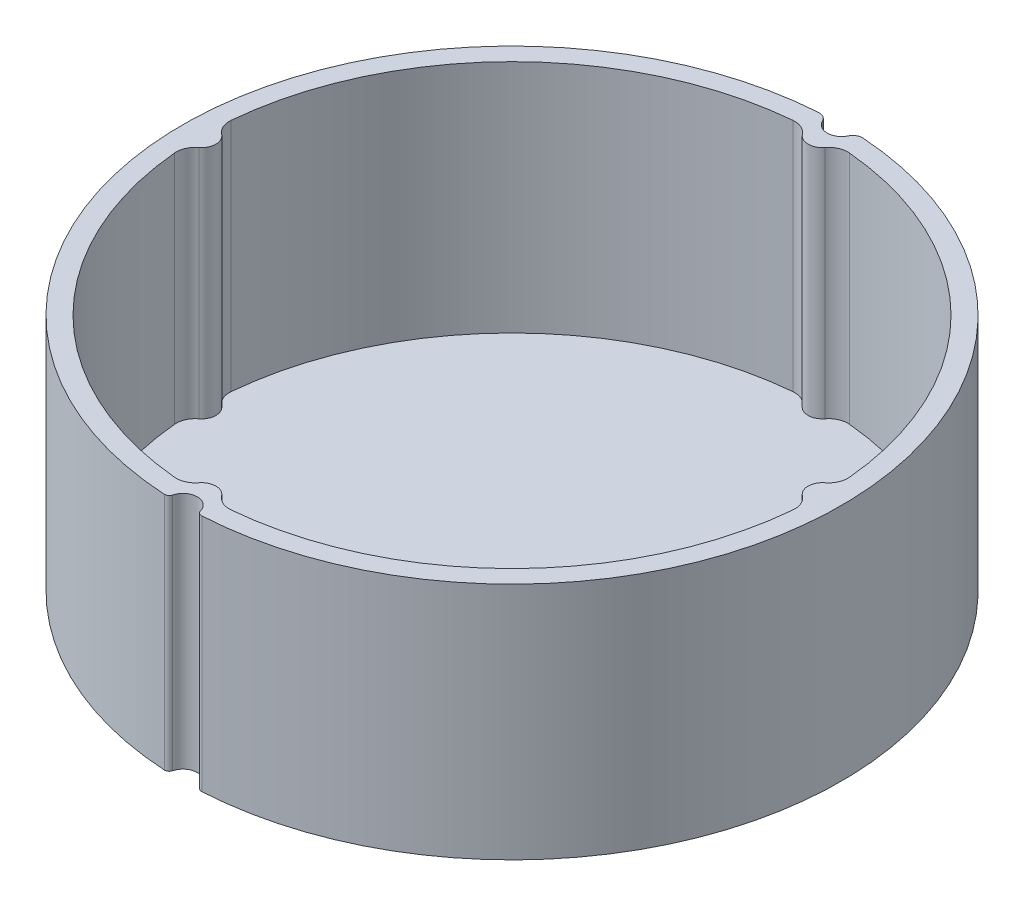
from build123d import *

# Parameters (mm, degrees)
BOSS_EXTRUDE1_DEPTH = 25
CUT_EXTRUDE2_DEPTH  = 55.786493398
BOSS_EXTRUDE2_DEPTH = 0.4


with BuildPart() as part:
    # Sketch1 → Boss-Extrude1 (new body)
    with BuildSketch(Plane(origin=(0, 0, 0), x_dir=(1, 0, 0), z_dir=(0, 1, 0))):
        with BuildLine():
            ThreePointArc((1.451818925, -34.068556857), (1.641248992, -34.346908706), (1.964225605, -34.442038138))
            ThreePointArc((1.964225605, -34.442038138), (26.591847487, -21.978073076), (34.198225299, 4.555174015))
            ThreePointArc((34.198225299, 4.555174015), (23.590291339, 25.176355888), (2.324135821, 34.423627607))
            ThreePointArc((2.324135821, 34.423627607), (1.751838249, 34.289058819), (1.354061739, 33.856153382))
            ThreePointArc((1.354061739, 33.856153382), (0, 33.001534515), (-1.354061739, 33.856153382))
            ThreePointArc((-1.354061739, 33.856153382), (-1.751838249, 34.289058819), (-2.324135821, 34.423627607))
            ThreePointArc((-2.324135821, 34.423627607), (-23.590291339, 25.176355888), (-34.198225299, 4.555174015))
            ThreePointArc((-34.198225299, 4.555174015), (-26.591847487, -21.978073076), (-1.964225605, -34.442038138))
            ThreePointArc((-1.964225605, -34.442038138), (-1.641248992, -34.346908706), (-1.451818925, -34.068556857))
            ThreePointArc((-1.451818925, -34.068556857), (0, -32.945679925), (1.451818925, -34.068556857))
        make_face()
        with BuildLine():
            Line((-2.417, 3.787737139), (0, 3.787737139))
            Line((0, 3.787737139), (2.417, 3.787737139))
            ThreePointArc((2.417, 3.787737139), (0, -4.489512172), (-2.417, 3.787737139))
        make_face(mode=Mode.SUBTRACT)
    extrude(amount=BOSS_EXTRUDE1_DEPTH)

    # Sketch2 → Cut-Extrude2 (cut, through all)
    with BuildSketch(Plane(origin=(0, 0, 0), x_dir=(1, 0, 0), z_dir=(0, 1, 0))):
        with BuildLine():
            ThreePointArc((-32.364754098, -2.961873082), (-22.980970389, -22.980970389), (-2.961873082, -32.364754098))
            ThreePointArc((-2.961873082, -32.364754098), (-1.976534873, -32.204764677), (-1.191258844, -31.588461538))
            ThreePointArc((-1.191258844, -31.588461538), (0, -31), (1.191258844, -31.588461538))
            ThreePointArc((1.191258844, -31.588461538), (1.976534873, -32.204764677), (2.961873082, -32.364754098))
            ThreePointArc((2.961873082, -32.364754098), (22.980970389, -22.980970389), (32.364754098, -2.961873082))
            ThreePointArc((32.364754098, -2.961873082), (32.204764677, -1.976534873), (31.588461538, -1.191258844))
            ThreePointArc((31.588461538, -1.191258844), (31, 0), (31.588461538, 1.191258844))
            ThreePointArc((31.588461538, 1.191258844), (32.204764677, 1.976534873), (32.364754098, 2.961873082))
            ThreePointArc((32.364754098, 2.961873082), (22.980970389, 22.980970389), (2.961873082, 32.364754098))
            ThreePointArc((2.961873082, 32.364754098), (1.976534873, 32.204764677), (1.191258844, 31.588461538))
            ThreePointArc((1.191258844, 31.588461538), (0, 31), (-1.191258844, 31.588461538))
            ThreePointArc((-1.191258844, 31.588461538), (-1.976534873, 32.204764677), (-2.961873082, 32.364754098))
            ThreePointArc((-2.961873082, 32.364754098), (-22.980970389, 22.980970389), (-32.364754098, 2.961873082))
            ThreePointArc((-32.364754098, 2.961873082), (-32.204764677, 1.976534873), (-31.588461538, 1.191258844))
            ThreePointArc((-31.588461538, 1.191258844), (-31, 0), (-31.588461538, -1.191258844))
            ThreePointArc((-31.588461538, -1.191258844), (-32.204764677, -1.976534873), (-32.364754098, -2.961873082))
        make_face()
    extrude(amount=CUT_EXTRUDE2_DEPTH, mode=Mode.SUBTRACT)

    # Sketch2_2 → Boss-Extrude2 (add)
    with BuildSketch(Plane(origin=(0, 0, 0), x_dir=(1, 0, 0), z_dir=(0, 1, 0))):
        with BuildLine():
            ThreePointArc((-32.364754098, -2.961873082), (-22.980970389, -22.980970389), (-2.961873082, -32.364754098))
            ThreePointArc((-2.961873082, -32.364754098), (-1.976534873, -32.204764677), (-1.191258844, -31.588461538))
            ThreePointArc((-1.191258844, -31.588461538), (0, -31), (1.191258844, -31.588461538))
            ThreePointArc((1.191258844, -31.588461538), (1.976534873, -32.204764677), (2.961873082, -32.364754098))
            ThreePointArc((2.961873082, -32.364754098), (22.980970389, -22.980970389), (32.364754098, -2.961873082))
            ThreePointArc((32.364754098, -2.961873082), (32.204764677, -1.976534873), (31.588461538, -1.191258844))
            ThreePointArc((31.588461538, -1.191258844), (31, 0), (31.588461538, 1.191258844))
            ThreePointArc((31.588461538, 1.191258844), (32.204764677, 1.976534873), (32.364754098, 2.961873082))
            ThreePointArc((32.364754098, 2.961873082), (22.980970389, 22.980970389), (2.961873082, 32.364754098))
            ThreePointArc((2.961873082, 32.364754098), (1.976534873, 32.204764677), (1.191258844, 31.588461538))
            ThreePointArc((1.191258844, 31.588461538), (0, 31), (-1.191258844, 31.588461538))
            ThreePointArc((-1.191258844, 31.588461538), (-1.976534873, 32.204764677), (-2.961873082, 32.364754098))
            ThreePointArc((-2.961873082, 32.364754098), (-22.980970389, 22.980970389), (-32.364754098, 2.961873082))
            ThreePointArc((-32.364754098, 2.961873082), (-32.204764677, 1.976534873), (-31.588461538, 1.191258844))
            ThreePointArc((-31.588461538, 1.191258844), (-31, 0), (-31.588461538, -1.191258844))
            ThreePointArc((-31.588461538, -1.191258844), (-32.204764677, -1.976534873), (-32.364754098, -2.961873082))
        make_face()
    extrude(amount=BOSS_EXTRUDE2_DEPTH)


solid = part.part
